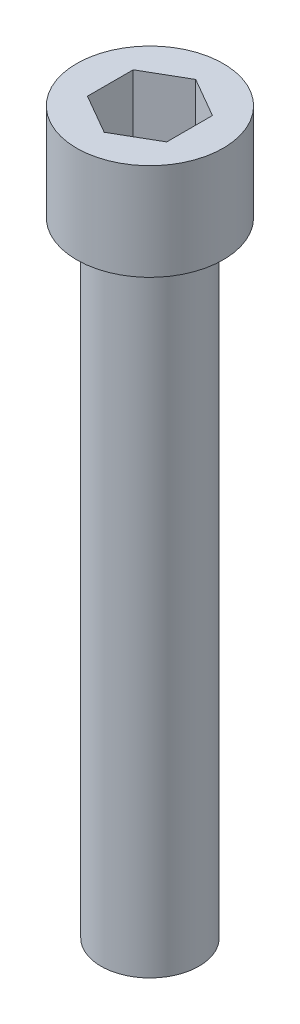
from build123d import *

# Parameters (mm, degrees)
SKETCH1_R           = 5.875
BOSS_EXTRUDE1_DEPTH = 7.75
CUT_EXTRUDE1_DEPTH  = 5.5
SKETCH3_R           = 3.925
BOSS_EXTRUDE2_DEPTH = 10
SKETCH4_R           = 3.925
BOSS_EXTRUDE3_DEPTH = 40


with BuildPart() as part:
    # Sketch1 → Boss-Extrude1 (new body)
    with BuildSketch(Plane(origin=(0, 0, 0), x_dir=(1, 0, 0), z_dir=(0, 1, 0))):
        Circle(SKETCH1_R)
    extrude(amount=BOSS_EXTRUDE1_DEPTH)

    # Sketch2 → Cut-Extrude1 (cut)
    with BuildSketch(Plane(origin=(0, 7.75, 0), x_dir=(1, 0, 0), z_dir=(0, 1, 0))):
        Polygon((0, 3.666174209), (-3.175, 1.833087105), (-3.175, -1.833087105), (0, -3.666174209), (3.175, -1.833087105), (3.175, 1.833087105), align=None)
    extrude(amount=-CUT_EXTRUDE1_DEPTH, mode=Mode.SUBTRACT)

    # Sketch3 → Boss-Extrude2 (add)
    with BuildSketch(Plane.XZ):
        Circle(SKETCH3_R)
    extrude(amount=BOSS_EXTRUDE2_DEPTH)

    # Sketch4 → Boss-Extrude3 (add)
    with BuildSketch(Plane.XZ.offset(10)):
        Circle(SKETCH4_R)
    extrude(amount=BOSS_EXTRUDE3_DEPTH)


solid = part.part
